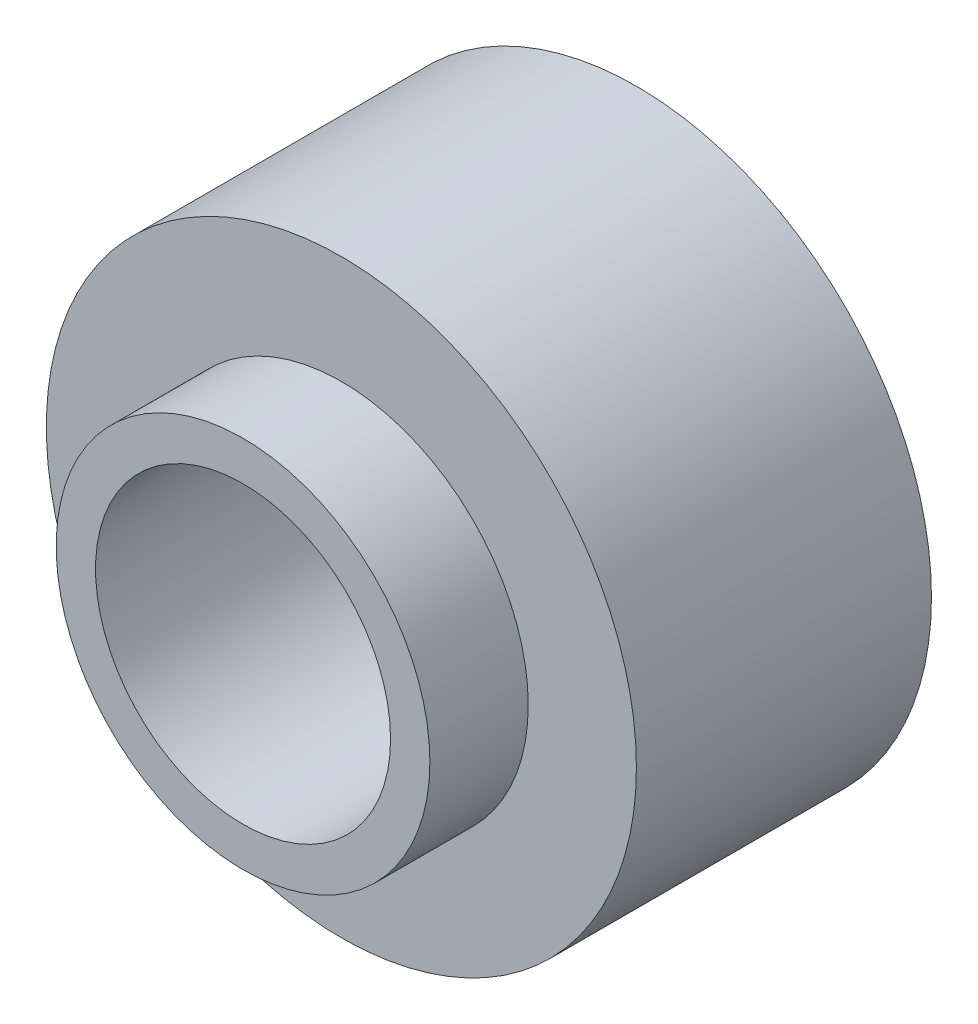
from build123d import *

# Parameters (mm, degrees)
SKETCH1_R           = 9.525
SKETCH1_R_2         = 4.7625
BOSS_EXTRUDE1_DEPTH = 9.525
BOSS_EXTRUDE2_START = 3.175
SKETCH1_4_R         = 6.0325
SKETCH1_4_R_2       = 4.7625
BOSS_EXTRUDE2_DEPTH = 3.175


with BuildPart() as part:
    # Sketch1 → Boss-Extrude1 (new body)
    with BuildSketch(Plane.XY):
        Circle(SKETCH1_R)
        Circle(SKETCH1_R_2, mode=Mode.SUBTRACT)
    extrude(amount=-BOSS_EXTRUDE1_DEPTH)

    # Sketch1_4 → Boss-Extrude2 (add)
    with BuildSketch(Plane.XY.offset(BOSS_EXTRUDE2_START)):
        Circle(SKETCH1_4_R)
        Circle(SKETCH1_4_R_2, mode=Mode.SUBTRACT)
    extrude(amount=-BOSS_EXTRUDE2_DEPTH)


solid = part.part
